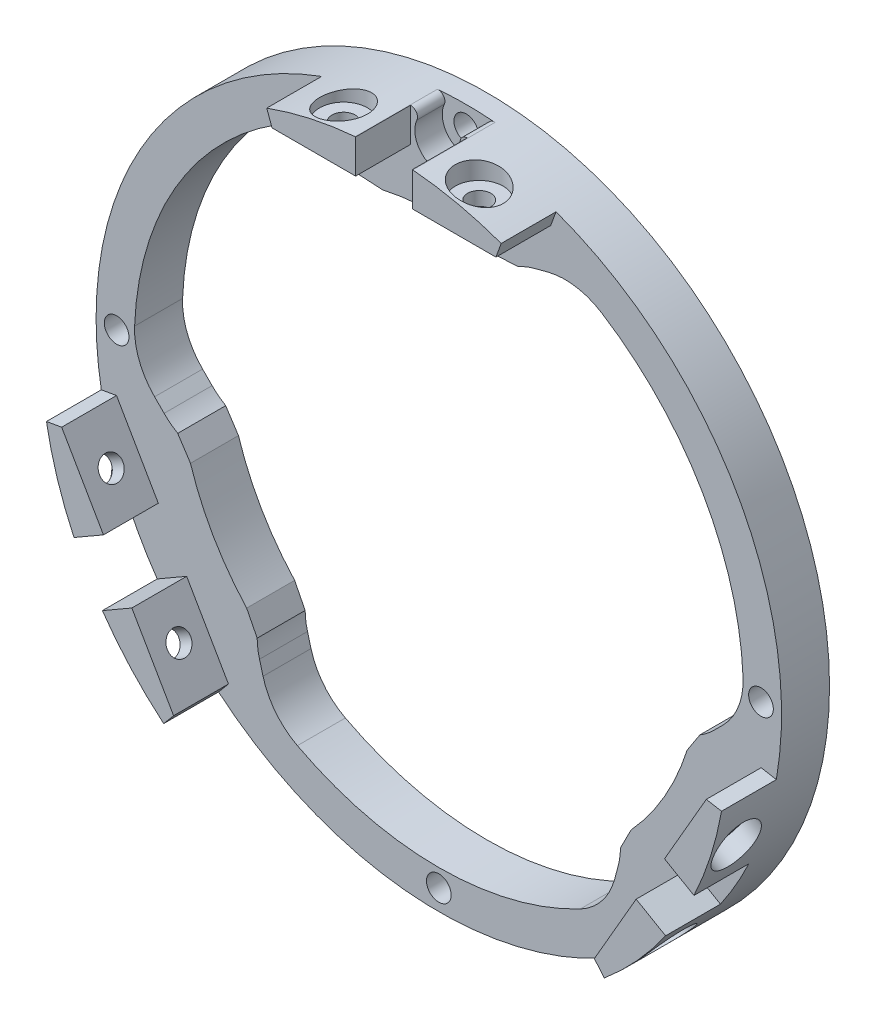
from build123d import *

# Parameters (mm, degrees)
SKETCH_1_W                   = 50
SKETCH_1_H                   = 7
CUT_EXTRUDE_1_DEPTH          = 4
CUT_EXTRUDE_2_DEPTH          = 8
EXTRUDE_1_DEPTH              = 8
EXTRUDE_2_DEPTH              = 8
EXTRUDE_3_DEPTH              = 8
EXTRUDE_4_DEPTH              = 8
EXTRUDE_5_DEPTH              = 8
EXTRUDE_6_DEPTH              = 8
HOLE_WIZARD_M3_1_D           = 3.4
HOLE_WIZARD_M3_1_DEPTH       = 117.890896659
HOLE_WIZARD_M3_1_CBORE_D     = 7
HOLE_WIZARD_M3_1_CBORE_DEPTH = 2.722101968
HOLE_WIZARD_M3_2_D           = 3.4
HOLE_WIZARD_M3_2_DEPTH       = 117.890896659
HOLE_WIZARD_M3_2_CBORE_D     = 7
HOLE_WIZARD_M3_2_CBORE_DEPTH = 2.722101968
HOLE_WIZARD_M3_3_D           = 3.4
HOLE_WIZARD_M3_3_DEPTH       = 99.58962647
HOLE_WIZARD_M3_3_CBORE_D     = 7
HOLE_WIZARD_M3_3_CBORE_DEPTH = 2.722101968
HOLE_WIZARD_3_6_3_6_1_D      = 3.6
HOLE_WIZARD_3_6_3_6_1_DEPTH  = 15
HOLE_WIZARD_3_6_3_6_2_D      = 3.6
HOLE_WIZARD_3_6_3_6_2_DEPTH  = 3
FILLET_1_R                   = 10


with BuildPart() as part:
    # 草图1 → 旋转1 (revolve)
    with BuildSketch(Plane.XZ.offset(-150)):
        with Locations((625, 3.5)):
            Rectangle(SKETCH_1_W, SKETCH_1_H)
    revolve(axis=Axis((600, 150, 7), (0, 0, -1)))

    # 草图2 → 切除-拉伸1 (cut)
    with BuildSketch(Plane.XY.offset(7)):
        with BuildLine():
            ThreePointArc((595.803701911, 199.823599653), (596.702458922, 199.406826168), (596.801488345, 198.421099291))
            ThreePointArc((596.801488345, 198.421099291), (600, 193.5), (603.198511655, 198.421099291))
            ThreePointArc((603.198511655, 198.421099291), (603.297541078, 199.406826168), (604.196298089, 199.823599653))
            ThreePointArc((604.196298089, 199.823599653), (600, 200), (595.803701911, 199.823599653))
        make_face()
    extrude(amount=-CUT_EXTRUDE_1_DEPTH, mode=Mode.SUBTRACT)

    # 草图3 → 切除-拉伸2 (cut, through all)
    with BuildSketch(Plane(origin=(0, 0, 0), x_dir=(-1, 0, 0), z_dir=(0, 0, -1))):
        with BuildLine():
            Line((-613.918146142, 188.239792245), (-619.734819826, 189.794276566))
            ThreePointArc((-619.734819826, 189.794276566), (-638.467982411, 172.2095), (-644.330264345, 147.193717025))
            Line((-644.330264345, 147.193717025), (-640.075704591, 142.93357201))
            ThreePointArc((-640.075704591, 142.93357201), (-639.132532117, 142.101136168), (-638.092310865, 141.393701722))
            Line((-638.092310865, 141.393701722), (-636.23143008, 138.542099914))
            ThreePointArc((-636.23143008, 138.542099914), (-632.908965344, 131), (-628.038547588, 124.351611178))
            Line((-628.038547588, 124.351611178), (-626.499428374, 121.314240241))
            ThreePointArc((-626.499428374, 121.314240241), (-626.406882798, 120.059664989), (-626.157558449, 118.826635745))
            Line((-626.157558449, 118.826635745), (-624.595444519, 113.012006408))
            ThreePointArc((-624.595444519, 113.012006408), (-600, 105.581), (-575.404555481, 113.012006408))
            Line((-575.404555481, 113.012006408), (-573.842441551, 118.826635745))
            ThreePointArc((-573.842441551, 118.826635745), (-573.593117202, 120.059664989), (-573.500571626, 121.314240241))
            Line((-573.500571626, 121.314240241), (-571.961452412, 124.351611178))
            ThreePointArc((-571.961452412, 124.351611178), (-567.091034656, 131), (-563.76856992, 138.542099914))
            Line((-563.76856992, 138.542099914), (-561.907689135, 141.393701722))
            ThreePointArc((-561.907689135, 141.393701722), (-560.867467883, 142.101136168), (-559.924295409, 142.93357201))
            Line((-559.924295409, 142.93357201), (-555.669735655, 147.193717025))
            ThreePointArc((-555.669735655, 147.193717025), (-561.532017589, 172.2095), (-580.265180174, 189.794276566))
            Line((-580.265180174, 189.794276566), (-586.081853858, 188.239792245))
            ThreePointArc((-586.081853858, 188.239792245), (-587.274350681, 187.839198844), (-588.407117509, 187.292058037))
            Line((-588.407117509, 187.292058037), (-591.807117509, 187.106288907))
            ThreePointArc((-591.807117509, 187.106288907), (-600, 188), (-608.192882491, 187.106288907))
            Line((-608.192882491, 187.106288907), (-611.592882491, 187.292058037))
            ThreePointArc((-611.592882491, 187.292058037), (-612.725649319, 187.839198844), (-613.918146142, 188.239792245))
        make_face()
    extrude(amount=-CUT_EXTRUDE_2_DEPTH, mode=Mode.SUBTRACT)

    # 草图4 → 凸台-拉伸1 (add)
    with BuildSketch(Plane.XY.offset(7)):
        with BuildLine():
            Line((595.862693304, 199.826816745), (595.862693304, 194.867524502))
            Line((595.862693304, 194.867524502), (583.669556596, 194.867524502))
            Line((583.669556596, 194.867524502), (582.898992834, 196.984631039))
            ThreePointArc((582.898992834, 196.984631039), (589.257154079, 198.832276841), (595.803701911, 199.823599653))
            ThreePointArc((595.803701911, 199.823599653), (595.833173844, 199.825643938), (595.862693304, 199.826816745))
        make_face()
    extrude(amount=EXTRUDE_1_DEPTH)

    # 草图5 → 凸台-拉伸2 (add)
    with BuildSketch(Plane.XY.offset(7)):
        with BuildLine():
            Line((617.101007166, 196.984631039), (616.330443404, 194.867524502))
            Line((616.330443404, 194.867524502), (604.137306696, 194.867524502))
            Line((604.137306696, 194.867524502), (604.137306696, 199.826816745))
            ThreePointArc((604.137306696, 199.826816745), (604.166826156, 199.825643938), (604.196298089, 199.823599653))
            ThreePointArc((604.196298089, 199.823599653), (610.742845921, 198.832276841), (617.101007166, 196.984631039))
        make_face()
    extrude(amount=EXTRUDE_2_DEPTH)

    # 草图6 → 凸台-拉伸3 (add)
    with BuildSketch(Plane.XY.offset(7)):
        with BuildLine():
            Line((563.212237324, 123.983225047), (569.308805678, 113.423658906))
            Line((569.308805678, 113.423658906), (567.860619516, 111.697777844))
            ThreePointArc((567.860619516, 111.697777844), (563.061475995, 116.302144811), (558.915878003, 121.502720836))
            Line((558.915878003, 121.502720836), (563.212237324, 123.983225047))
        make_face()
    extrude(amount=EXTRUDE_3_DEPTH)

    # 草图7 → 凸台-拉伸4 (add)
    with BuildSketch(Plane.XY.offset(7)):
        with BuildLine():
            Line((559.074930628, 131.149250451), (554.778571307, 128.66874624))
            ThreePointArc((554.778571307, 128.66874624), (552.347539351, 134.859227428), (550.759612349, 141.317591117))
            Line((550.759612349, 141.317591117), (552.978362274, 141.708816592))
            Line((552.978362274, 141.708816592), (559.074930628, 131.149250451))
        make_face()
    extrude(amount=EXTRUDE_4_DEPTH)

    # 草图8 → 凸台-拉伸5 (add)
    with BuildSketch(Plane.XY.offset(7)):
        with BuildLine():
            Line((640.925069372, 131.149250451), (647.021637726, 141.708816592))
            Line((647.021637726, 141.708816592), (649.240387651, 141.317591117))
            ThreePointArc((649.240387651, 141.317591117), (647.652460649, 134.859227428), (645.221428693, 128.66874624))
            Line((645.221428693, 128.66874624), (640.925069372, 131.149250451))
        make_face()
    extrude(amount=EXTRUDE_5_DEPTH)

    # 草图9 → 凸台-拉伸6 (add)
    with BuildSketch(Plane.XY.offset(7)):
        with BuildLine():
            Line((636.787762676, 123.983225047), (641.084121997, 121.502720836))
            ThreePointArc((641.084121997, 121.502720836), (636.938524005, 116.302144811), (632.139380484, 111.697777844))
            Line((632.139380484, 111.697777844), (630.691194322, 113.423658906))
            Line((630.691194322, 113.423658906), (636.787762676, 123.983225047))
        make_face()
    extrude(amount=EXTRUDE_6_DEPTH)

    # M3 六角头机械螺钉的柱形沉头孔1
    with Locations(Plane(origin=(427.993971004, -247.10243437, 0), x_dir=(0, 0, -1), z_dir=(0.866025404, -0.5, 0))):
        with Locations((-11, 420.010928076), (-11, 439.796693059)):
            CounterBoreHole(HOLE_WIZARD_M3_1_D / 2, HOLE_WIZARD_M3_1_CBORE_D / 2, HOLE_WIZARD_M3_1_CBORE_DEPTH, depth=HOLE_WIZARD_M3_1_DEPTH)

    # M3 六角头机械螺钉的柱形沉头孔2
    with Locations(Plane(origin=(472.006028996, 272.5128079, 0), x_dir=(0, 0, 1), z_dir=(-0.866025404, -0.5, 0))):
        with Locations((11, -160.203306941), (11, -179.989071924)):
            CounterBoreHole(HOLE_WIZARD_M3_2_D / 2, HOLE_WIZARD_M3_2_CBORE_D / 2, HOLE_WIZARD_M3_2_CBORE_DEPTH, depth=HOLE_WIZARD_M3_2_DEPTH)

    # M3 六角头机械螺钉的柱形沉头孔3
    with Locations(Plane(origin=(0, 199.58962647, 0), x_dir=(1, 0, 0), z_dir=(0, 1, 0))):
        with Locations((609.892882491, -11), (590.107117509, -11)):
            CounterBoreHole(HOLE_WIZARD_M3_3_D / 2, HOLE_WIZARD_M3_3_CBORE_D / 2, HOLE_WIZARD_M3_3_CBORE_DEPTH, depth=HOLE_WIZARD_M3_3_DEPTH)

    # Ø3.6 (3.6) 直径孔1
    with Locations(Plane(origin=(0, 0, 0), x_dir=(-1, 0, 0), z_dir=(0, 0, -1))):
        with Locations((-600, 103), (-647, 150), (-553, 150)):
            Hole(HOLE_WIZARD_3_6_3_6_1_D / 2, depth=HOLE_WIZARD_3_6_3_6_1_DEPTH)

    # Ø3.6 (3.6) 直径孔2
    with Locations(Plane.XY.offset(3)):
        with Locations((600, 197)):
            Hole(HOLE_WIZARD_3_6_3_6_2_D / 2, depth=HOLE_WIZARD_3_6_3_6_2_DEPTH)

    # 圆角1
    fillet_1_edges = [part.edges().sort_by_distance(p)[0] for p in [
        (580.265180174, 189.794276566, 3.5),
        (555.669735655, 147.193717025, 3.5),
        (575.404555481, 113.012006408, 3.5),
        (624.595444519, 113.012006408, 3.5),
        (644.330264345, 147.193717025, 3.5),
        (619.734819826, 189.794276566, 3.5),
    ]]
    fillet(fillet_1_edges, radius=FILLET_1_R)


solid = part.part
